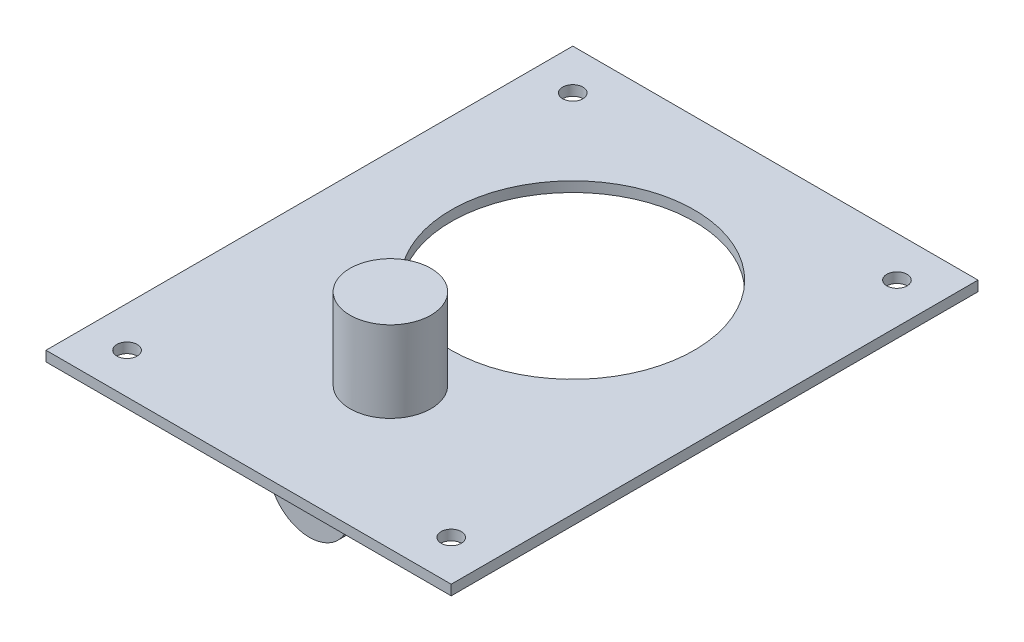
from build123d import *

# Parameters (mm, degrees)
SKETCH1_R           = 76.2
BOSS_EXTRUDE1_DEPTH = 3.175
SKETCH2_R           = 25.4
BOSS_EXTRUDE2_DEPTH = 50.8
SKETCH3_R           = 6.35
CUT_EXTRUDE1_DEPTH  = 245.948729329
BOSS_EXTRUDE3_START = 114.3
SKETCH4_R           = 25.4
BOSS_EXTRUDE3_DEPTH = 50.8


with BuildPart() as part:
    # Sketch1 → Boss-Extrude1 (new, symmetric)
    with BuildSketch(Plane(origin=(0, 0, 0), x_dir=(1, 0, 0), z_dir=(0, 1, 0))):
        Polygon((-127, -127), (-127, 127), (127, 127), (127, -127), (127, -203.2), (-127, -203.2), align=None)
        Circle(SKETCH1_R, mode=Mode.SUBTRACT)
    extrude(amount=BOSS_EXTRUDE1_DEPTH, both=True)

    # Sketch2 → Boss-Extrude2 (add)
    with BuildSketch(Plane(origin=(0, 3.175, 0), x_dir=(1, 0, 0), z_dir=(0, 1, 0))):
        with Locations((0, -114.3)):
            Circle(SKETCH2_R)
    extrude(amount=BOSS_EXTRUDE2_DEPTH)

    # Sketch3 → Cut-Extrude1 (cut, through all)
    with BuildSketch(Plane(origin=(0, 3.175, 0), x_dir=(1, 0, 0), z_dir=(0, 1, 0))):
        with Locations((-101.6, 101.6)):
            Circle(SKETCH3_R)
        with Locations((-101.6, -177.8)):
            Circle(SKETCH3_R)
    cut_extrude1 = extrude(amount=-CUT_EXTRUDE1_DEPTH, mode=Mode.SUBTRACT)

    # Mirror1: Cut-Extrude1 across plane
    add(cut_extrude1.mirror(Plane(origin=(0, 0, 0), x_dir=(0, 0, 1), z_dir=(1, 0, 0))), mode=Mode.SUBTRACT)


with BuildPart() as body_2:
    # Sketch4 → Boss-Extrude3 (new body)
    with BuildSketch(Plane.XY.offset(BOSS_EXTRUDE3_START)):
        with Locations((0, -28.575)):
            Circle(SKETCH4_R)
    extrude(amount=BOSS_EXTRUDE3_DEPTH)


solid = Compound([part.part, body_2.part])
